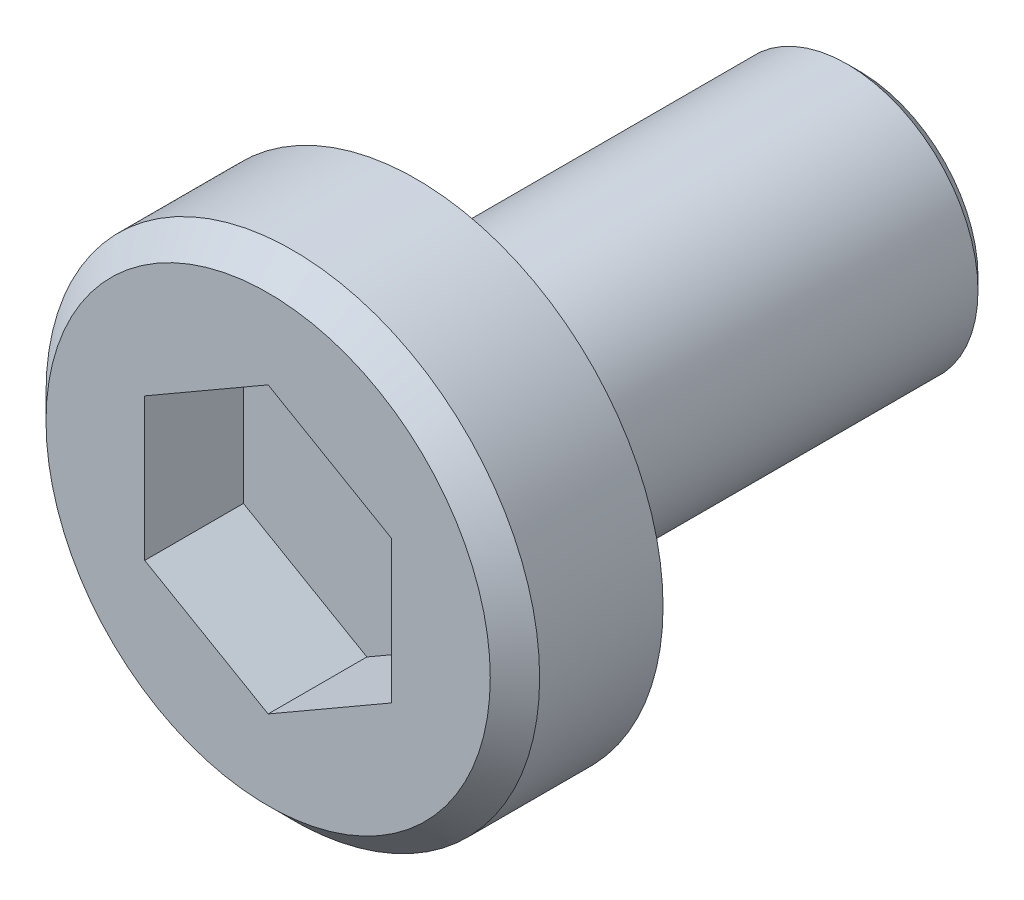
from build123d import *

# Parameters (mm, degrees)
CUT_EXTRUDE2_DEPTH = 2
CHAMFER1_SIZE      = 0.5
CHAMFER2_SIZE      = 0.25


with BuildPart() as part:
    # Sketch1 → Revolve1 (revolve)
    with BuildSketch(Plane(origin=(0, 0, 0), x_dir=(0, 0, -1), z_dir=(1, 0, 0))):
        Polygon((0, 0), (0, 5), (3, 5), (3, 2.65), (11.98, 2.65), (11.98, 0), align=None)
    revolve(axis=Axis((0, 0, 0), (0, 0, -1)))

    # Sketch2 → Cut-Extrude2 (cut)
    with BuildSketch(Plane.XY):
        Polygon((0, 2.886751346), (-2.5, 1.443375673), (-2.5, -1.443375673), (0, -2.886751346), (2.5, -1.443375673), (2.5, 1.443375673), align=None)
    extrude(amount=-CUT_EXTRUDE2_DEPTH, mode=Mode.SUBTRACT)

    # Chamfer1
    chamfer1_edges = [part.edges().sort_by_distance(p)[0] for p in [
        (0, -5, 0),
    ]]
    chamfer(chamfer1_edges, length=CHAMFER1_SIZE)

    # Chamfer2
    chamfer2_edges = [part.edges().sort_by_distance(p)[0] for p in [
        (0, -2.65, -11.98),
    ]]
    chamfer(chamfer2_edges, length=CHAMFER2_SIZE)


solid = part.part
